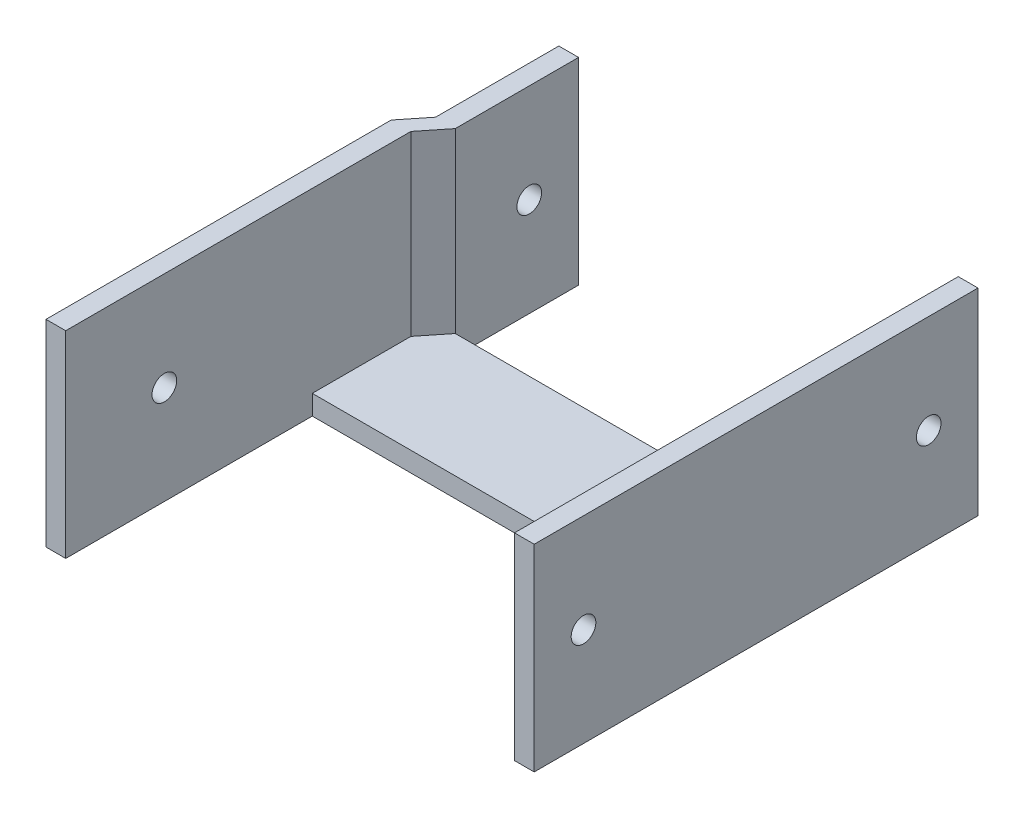
from build123d import *

# Parameters (mm, degrees)
SALIENTE_EXTRUIR1_DEPTH = 105
CROQUIS3_W              = 4
CROQUIS3_H              = 30
SALIENTE_EXTRUIR2_DEPTH = 30
CROQUIS4_W              = 77
CROQUIS4_H              = 30
CORTAR_EXTRUIR1_DEPTH   = 30
CROQUIS5_W              = 81
CROQUIS5_H              = 50
CORTAR_EXTRUIR2_DEPTH   = 30
CROQUIS6_W              = 4
CROQUIS6_H              = 30
CORTAR_EXTRUIR3_DEPTH   = 70
SALIENTE_EXTRUIR4_DEPTH = 40
CROQUIS7_W              = 30
CROQUIS7_H              = 6
SALIENTE_EXTRUIR5_DEPTH = 4
CROQUIS10_W             = 5
CROQUIS10_H             = 40
CORTAR_EXTRUIR5_DEPTH   = 4
CROQUIS11_W             = 10
CROQUIS11_H             = 40
CORTAR_EXTRUIR6_DEPTH   = 4
CROQUIS12_R             = 2.5
CORTAR_EXTRUIR7_DEPTH   = 90
CROQUIS13_W             = 5
CROQUIS13_H             = 40
CORTAR_EXTRUIR8_DEPTH   = 10


with BuildPart() as part:
    # Croquis2 → Saliente-Extruir1 (new body)
    with BuildSketch(Plane.XY):
        Polygon((47.018573694, 40), (43.018573694, 40), (43.018573694, 4), (-37.981426306, 4), (-37.981426306, 40), (-41.981426306, 40), (-41.981426306, 0), (47.018573694, 0), align=None)
    extrude(amount=SALIENTE_EXTRUIR1_DEPTH)

    # Croquis3 → Saliente-Extruir2 (add)
    with BuildSketch(Plane.XY):
        with Locations((-35.981426306, 25)):
            Rectangle(CROQUIS3_W, CROQUIS3_H)
    extrude(amount=SALIENTE_EXTRUIR2_DEPTH)

    # Croquis4 → Cortar-Extruir1 (cut)
    with BuildSketch(Plane(origin=(0, 4, 0), x_dir=(1, 0, 0), z_dir=(0, 1, 0))):
        with Locations((4.518573694, -15)):
            Rectangle(CROQUIS4_W, CROQUIS4_H)
    extrude(amount=-CORTAR_EXTRUIR1_DEPTH, mode=Mode.SUBTRACT)

    # Croquis5 → Cortar-Extruir2 (cut)
    with BuildSketch(Plane(origin=(0, 4, 0), x_dir=(1, 0, 0), z_dir=(0, 1, 0))):
        with Locations((2.518573694, -80)):
            Rectangle(CROQUIS5_W, CROQUIS5_H)
    extrude(amount=-CORTAR_EXTRUIR2_DEPTH, mode=Mode.SUBTRACT)

    # Croquis6 → Cortar-Extruir3 (cut)
    with BuildSketch(Plane(origin=(0, 40, 0), x_dir=(1, 0, 0), z_dir=(0, 1, 0))):
        with Locations((-39.981426306, -15)):
            Rectangle(CROQUIS6_W, CROQUIS6_H)
        Polygon((-41.981426306, -30), (-41.981426306, -35), (-37.981426306, -30), align=None)
    extrude(amount=-CORTAR_EXTRUIR3_DEPTH, mode=Mode.SUBTRACT)

    # Croquis8 → Saliente-Extruir4 (add)
    with BuildSketch(Plane(origin=(0, 40, 0), x_dir=(1, 0, 0), z_dir=(0, 1, 0))):
        Polygon((-37.981426306, -30), (-33.981426306, -30), (-37.981426306, -35), align=None)
    extrude(amount=-SALIENTE_EXTRUIR4_DEPTH)

    # Croquis7 → Saliente-Extruir5 (add)
    with BuildSketch(Plane.ZY.offset(37.981426306)):
        with Locations((15, 7)):
            Rectangle(CROQUIS7_W, CROQUIS7_H)
    extrude(amount=-SALIENTE_EXTRUIR5_DEPTH)

    # Croquis10 → Cortar-Extruir5 (cut)
    with BuildSketch(Plane(origin=(47.018573694, 0, 0), x_dir=(0, 0, -1), z_dir=(1, 0, 0))):
        with Locations((-2.5, 20)):
            Rectangle(CROQUIS10_W, CROQUIS10_H)
    extrude(amount=-CORTAR_EXTRUIR5_DEPTH, mode=Mode.SUBTRACT)

    # Croquis11 → Cortar-Extruir6 (cut)
    with BuildSketch(Plane(origin=(47.018573694, 0, 0), x_dir=(0, 0, -1), z_dir=(1, 0, 0))):
        with Locations((-100, 20)):
            Rectangle(CROQUIS11_W, CROQUIS11_H)
    extrude(amount=-CORTAR_EXTRUIR6_DEPTH, mode=Mode.SUBTRACT)

    # Croquis12 → Cortar-Extruir7 (cut, through all)
    with BuildSketch(Plane(origin=(47.018573694, 0, 0), x_dir=(0, 0, -1), z_dir=(1, 0, 0))):
        with Locations((-15, 20)):
            Circle(CROQUIS12_R)
        with Locations((-85, 20)):
            Circle(CROQUIS12_R)
    extrude(amount=-CORTAR_EXTRUIR7_DEPTH, mode=Mode.SUBTRACT)

    # Croquis13 → Cortar-Extruir8 (cut)
    with BuildSketch(Plane.ZY.offset(37.981426306)):
        with Locations((2.5, 20)):
            Rectangle(CROQUIS13_W, CROQUIS13_H)
    extrude(amount=-CORTAR_EXTRUIR8_DEPTH, mode=Mode.SUBTRACT)


solid = part.part
